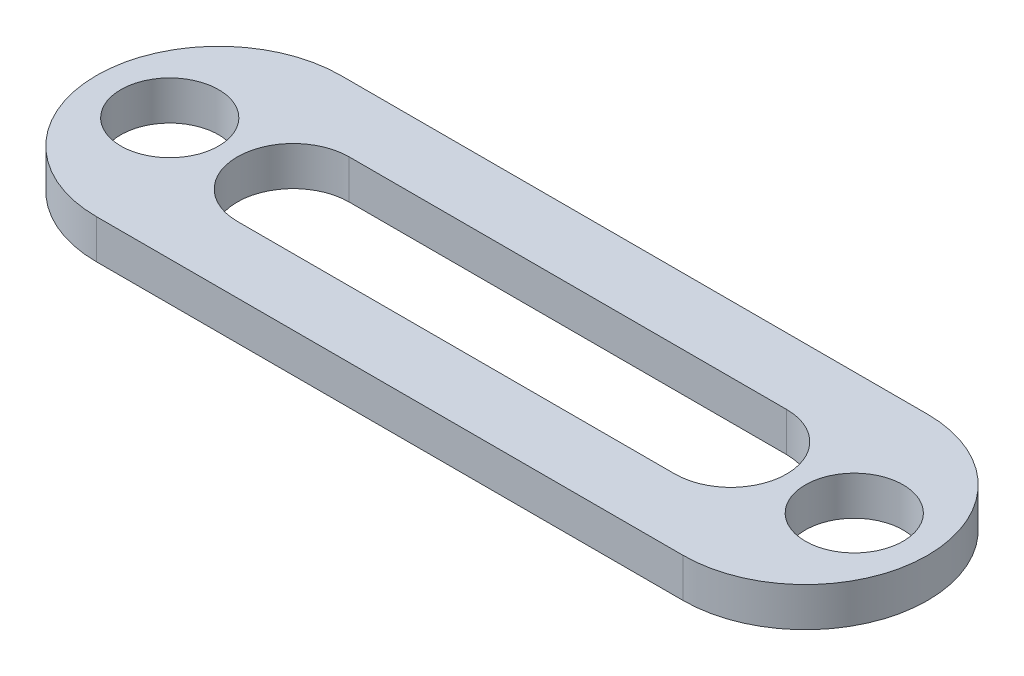
from build123d import *

# Parameters (mm, degrees)
SKETCH1_R           = 1.27
BOSS_EXTRUDE4_DEPTH = 1.016


with BuildPart() as part:
    # Sketch1 → Boss-Extrude4 (new body)
    with BuildSketch(Plane(origin=(0, 0, 0), x_dir=(1, 0, 0), z_dir=(0, 1, 0))):
        with BuildLine():
            Line((0, 3.175), (15.24, 3.175))
            ThreePointArc((15.24, 3.175), (18.415, 0), (15.24, -3.175))
            Line((15.24, -3.175), (0, -3.175))
            ThreePointArc((0, -3.175), (-3.175, 0), (0, 3.175))
        make_face()
        with Locations((-1.27, 0)):
            Circle(SKETCH1_R, mode=Mode.SUBTRACT)
        with Locations((16.51, 0)):
            Circle(SKETCH1_R, mode=Mode.SUBTRACT)
        with BuildLine():
            Line((1.937217735, 1.451749021), (13.302782265, 1.451749021))
            ThreePointArc((13.302782265, 1.451749021), (14.754531286, 0), (13.302782265, -1.451749021))
            Line((13.302782265, -1.451749021), (1.937217735, -1.451749021))
            ThreePointArc((1.937217735, -1.451749021), (0.485468714, 0), (1.937217735, 1.451749021))
        make_face(mode=Mode.SUBTRACT)
    extrude(amount=BOSS_EXTRUDE4_DEPTH)


solid = part.part
